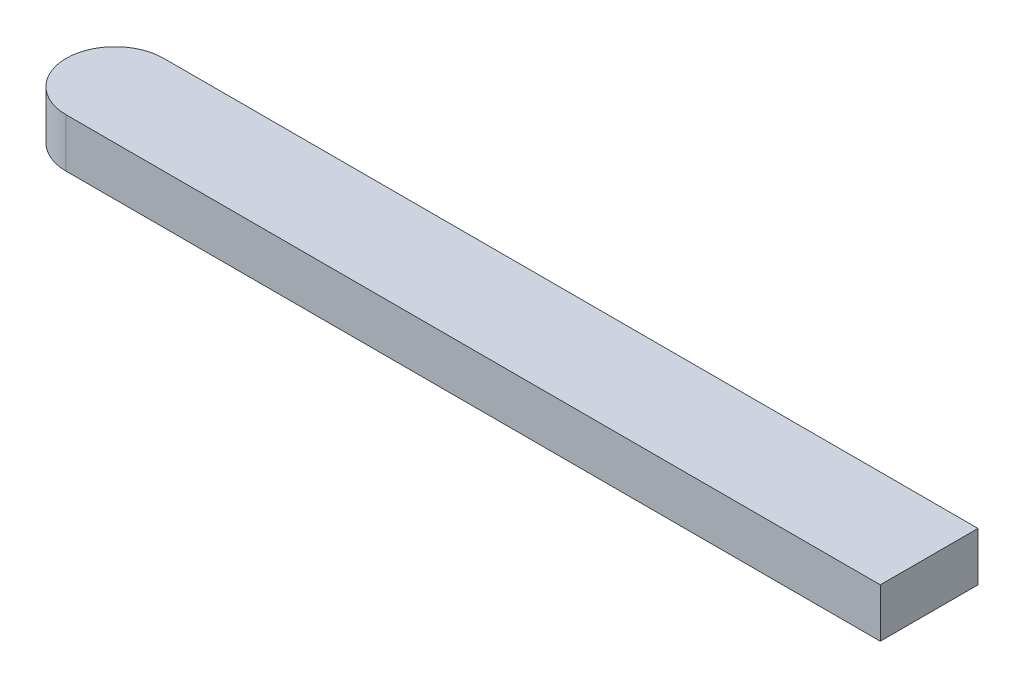
from build123d import *

# Parameters (mm, degrees)
SKETCH_1_R      = 3
SKETCH_1_W      = 50
SKETCH_1_H      = 6
EXTRUDE_1_DEPTH = 3


with BuildPart() as part:
    # 草图1 → 凸台-拉伸1 (new body)
    with BuildSketch(Plane(origin=(0, 0, 0), x_dir=(1, 0, 0), z_dir=(0, 1, 0))):
        Circle(SKETCH_1_R)
        with Locations((25, 0)):
            Rectangle(SKETCH_1_W, SKETCH_1_H)
    extrude(amount=EXTRUDE_1_DEPTH)


solid = part.part
